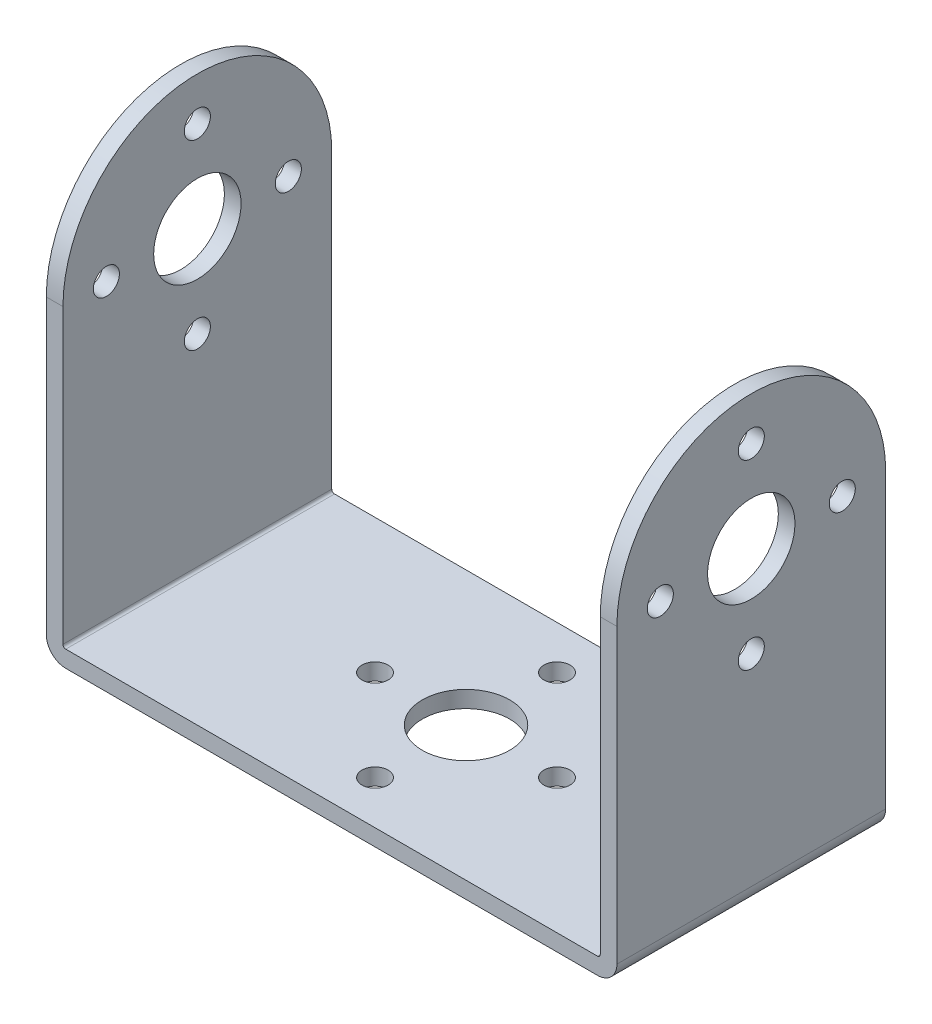
from build123d import *

# Parameters (mm, degrees)
SKETCH1_W               = 49.1998
SKETCH1_H               = 24.6126
SKETCH1_R               = 1.1938
SKETCH1_R_2             = 4.0005
EXTRUDE1_DEPTH          = 1.524
SKETCH1_3_W             = 1.524
SKETCH1_3_H             = 24.6126
EXTRUDE2_DEPTH          = 40.8686
SKETCH4_R               = 4.0005
SKETCH4_R_2             = 1.1938
CUT_EXTRUDE1_DEPTH      = 40.8686
CUT_EXTRUDE1_DEPTH_BACK = 40.8686
FILLET1_R               = 0.254
FILLET2_R               = 1.778


with BuildPart() as part:
    # Sketch1 → Extrude1 (new body)
    with BuildSketch(Plane(origin=(0, 0, 0), x_dir=(1, 0, 0), z_dir=(0, 1, 0))):
        Rectangle(SKETCH1_W, SKETCH1_H)
        with Locations((-8.3312, 0)):
            Circle(SKETCH1_R, mode=Mode.SUBTRACT)
        with Locations((0, -8.3312)):
            Circle(SKETCH1_R, mode=Mode.SUBTRACT)
        Circle(SKETCH1_R_2, mode=Mode.SUBTRACT)
        with Locations((8.3312, 0)):
            Circle(SKETCH1_R, mode=Mode.SUBTRACT)
        with Locations((0, 8.3312)):
            Circle(SKETCH1_R, mode=Mode.SUBTRACT)
    extrude(amount=EXTRUDE1_DEPTH)

    # Sketch1_3 → Extrude2 (add)
    with BuildSketch(Plane(origin=(0, 0, 0), x_dir=(1, 0, 0), z_dir=(0, 1, 0))):
        with Locations((25.3619, 0)):
            Rectangle(SKETCH1_3_W, SKETCH1_3_H)
        with Locations((-25.3619, 0)):
            Rectangle(SKETCH1_3_W, SKETCH1_3_H)
    extrude(amount=EXTRUDE2_DEPTH)

    # Sketch4 → Cut-Extrude1 (cut, two sides)
    with BuildSketch(Plane(origin=(0, 0, 0), x_dir=(0, 0, -1), z_dir=(1, 0, 0))) as cut_extrude1_sk:
        with BuildLine():
            Line((0, 40.8686), (-12.3063, 40.8686))
            Line((-12.3063, 40.8686), (-12.3063, 28.5623))
            ThreePointArc((-12.3063, 28.5623), (-8.701868181, 37.264168181), (0, 40.8686))
        make_face()
        with BuildLine():
            Line((12.3063, 40.8686), (0, 40.8686))
            ThreePointArc((0, 40.8686), (8.701868181, 37.264168181), (12.3063, 28.5623))
            Line((12.3063, 28.5623), (12.3063, 40.8686))
        make_face()
        with Locations((0, 28.575)):
            Circle(SKETCH4_R)
        with Locations((8.3312, 28.575)):
            Circle(SKETCH4_R_2)
        with Locations((0, 36.9062)):
            Circle(SKETCH4_R_2)
        with Locations((-8.3312, 28.575)):
            Circle(SKETCH4_R_2)
        with Locations((0, 20.2438)):
            Circle(SKETCH4_R_2)
    extrude(amount=CUT_EXTRUDE1_DEPTH, mode=Mode.SUBTRACT)
    extrude(cut_extrude1_sk.sketch, amount=-CUT_EXTRUDE1_DEPTH_BACK, mode=Mode.SUBTRACT)

    # Fillet1
    fillet1_edges = [part.edges().sort_by_distance(p)[0] for p in [
        (-24.5999, 1.524, 0),
        (24.5999, 1.524, 0),
    ]]
    fillet(fillet1_edges, radius=FILLET1_R)

    # Fillet2
    fillet2_edges = [part.edges().sort_by_distance(p)[0] for p in [
        (-26.1239, 0, 0),
        (26.1239, 0, 0),
    ]]
    fillet(fillet2_edges, radius=FILLET2_R)


solid = part.part
